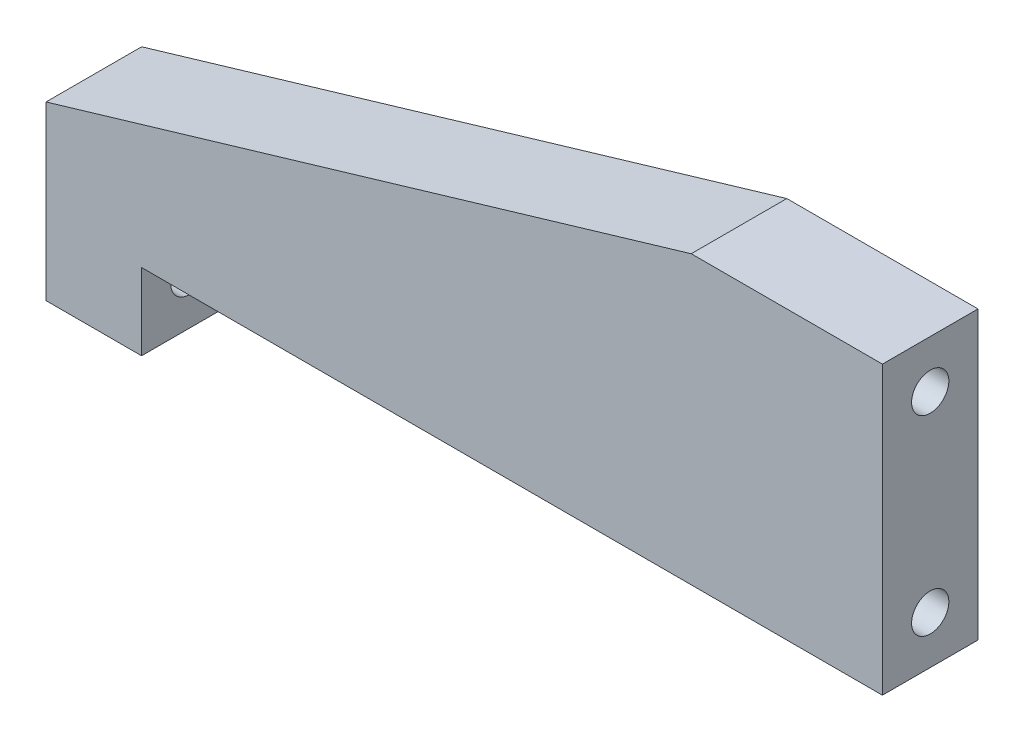
from build123d import *

# Parameters (mm, degrees)
EXTRUDE1_DEPTH                         = 10
F_4_0_4_DIAMETER_HOLE1_D               = 3.9
F_4_0_4_DIAMETER_HOLE1_DEPTH           = 15
F_4_0_4_DIAMETER_HOLE1_ON_FACE_2_D     = 3.9
F_4_0_4_DIAMETER_HOLE1_ON_FACE_2_DEPTH = 15
SKETCH3_W                              = 10
SKETCH3_H                              = 8
EXTRUDE2_DEPTH                         = 10
F_4_0_4_DIAMETER_HOLE2_D               = 3.9
F_4_0_4_DIAMETER_HOLE2_DEPTH           = 15


with BuildPart() as part:
    # Sketch1 → Extrude1 (new body)
    with BuildSketch(Plane.XY):
        Polygon((-43.75, -15), (-43.75, -5), (23.75, 15), (43.75, 15), (43.75, -15), align=None)
    extrude(amount=EXTRUDE1_DEPTH)

    # Ø4.0 (4) Diameter Hole1
    with Locations(Plane(origin=(-43.75, -10, 5), x_dir=(0, 0, -1), z_dir=(-1, 0, 0))):
        with Locations((0, 0)):
            Hole(F_4_0_4_DIAMETER_HOLE1_D / 2, depth=F_4_0_4_DIAMETER_HOLE1_DEPTH)

    # Ø4.0 (4) Diameter Hole1 on face 2
    with Locations(Plane(origin=(43.75, -10, 5), x_dir=(0, 0, 1), z_dir=(1, 0, 0))):
        with Locations((0, 0), (0, -20)):
            Hole(F_4_0_4_DIAMETER_HOLE1_ON_FACE_2_D / 2, depth=F_4_0_4_DIAMETER_HOLE1_ON_FACE_2_DEPTH)

    # Sketch3 → Extrude2 (add)
    with BuildSketch(Plane.XY):
        with Locations((-38.75, -19)):
            Rectangle(SKETCH3_W, SKETCH3_H)
    extrude(amount=EXTRUDE2_DEPTH)

    # Ø4.0 (4) Diameter Hole2
    with Locations(Plane(origin=(-43.75, -18, 5), x_dir=(0, 0, -1), z_dir=(-1, 0, 0))):
        with Locations((0, 0)):
            Hole(F_4_0_4_DIAMETER_HOLE2_D / 2, depth=F_4_0_4_DIAMETER_HOLE2_DEPTH)


solid = part.part
